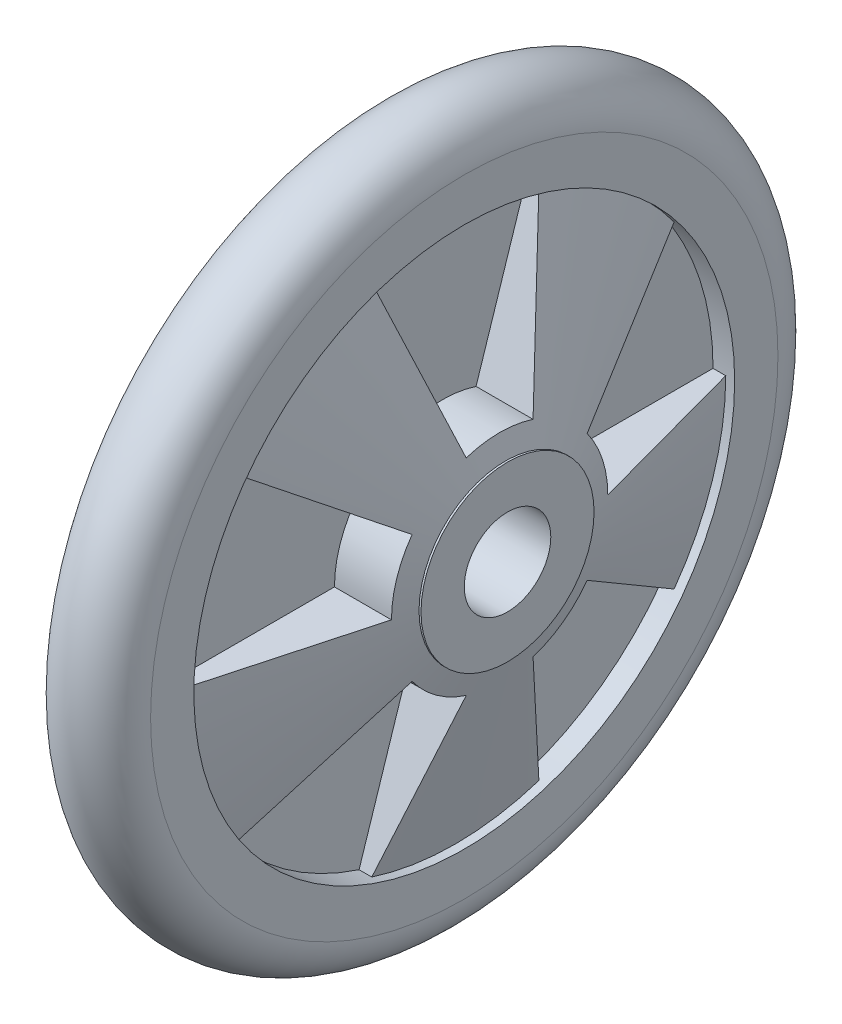
from build123d import *

# Parameters (mm, degrees)
SKETCH4_R            = 72.5
BOSS_EXTRUDE7_DEPTH  = 25
SKETCH13_R           = 72.5
BOSS_EXTRUDE8_DEPTH  = 5
SKETCH14_R           = 20
CUT_EXTRUDE1_DEPTH   = 25
SKETCH15_R           = 20
SKETCH15_R_2         = 10
BOSS_EXTRUDE10_DEPTH = 20


with BuildPart() as part:
    # Sweep1: sweep along a path in Sketch1
    with BuildLine(Plane(origin=(0, 0, 0), x_dir=(0, 0, -1), z_dir=(1, 0, 0))) as sweep1_path:
        CenterArc((0, 0), 72.5, 0, 360)
    # Sketch3 → Sweep1 (sweep)
    with BuildSketch(Plane.XY):
        with BuildLine():
            Line((10, 72.5), (10, 62.5))
            Line((10, 62.5), (-10, 62.5))
            Line((-10, 62.5), (-10, 72.5))
            ThreePointArc((-10, 72.5), (0, 82.5), (10, 72.5))
        make_face()
    sweep(path=sweep1_path.line)



with BuildPart() as body_2:
    # Sketch4 → Boss-Extrude7 (new body, symmetric)
    with BuildSketch(Plane(origin=(0, 0, 0), x_dir=(0, 0, -1), z_dir=(1, 0, 0))):
        Circle(SKETCH4_R)
        with BuildLine():
            Line((25, 0), (62.5, 0))
            ThreePointArc((62.5, 0), (59.441032268, 19.313562148), (50.563562148, 36.736578268))
            Line((50.563562148, 36.736578268), (20.225424859, 14.694631307))
            ThreePointArc((20.225424859, 14.694631307), (23.776412907, 7.725424859), (25, 0))
        make_face(mode=Mode.SUBTRACT)
        with BuildLine():
            Line((7.725424859, 23.776412907), (19.313562148, 59.441032268))
            ThreePointArc((19.313562148, 59.441032268), (0, 62.5), (-19.313562148, 59.441032268))
            Line((-19.313562148, 59.441032268), (-7.725424859, 23.776412907))
            ThreePointArc((-7.725424859, 23.776412907), (0, 25), (7.725424859, 23.776412907))
        make_face(mode=Mode.SUBTRACT)
        with BuildLine():
            Line((7.725424859, -23.776412907), (19.313562148, -59.441032268))
            ThreePointArc((19.313562148, -59.441032268), (36.736578268, -50.563562148), (50.563562148, -36.736578268))
            Line((50.563562148, -36.736578268), (20.225424859, -14.694631307))
            ThreePointArc((20.225424859, -14.694631307), (14.694631307, -20.225424859), (7.725424859, -23.776412907))
        make_face(mode=Mode.SUBTRACT)
        with BuildLine():
            Line((-20.225424859, -14.694631307), (-50.563562148, -36.736578268))
            ThreePointArc((-50.563562148, -36.736578268), (-36.736578268, -50.563562148), (-19.313562148, -59.441032268))
            Line((-19.313562148, -59.441032268), (-7.725424859, -23.776412907))
            ThreePointArc((-7.725424859, -23.776412907), (-14.694631307, -20.225424859), (-20.225424859, -14.694631307))
        make_face(mode=Mode.SUBTRACT)
        with BuildLine():
            Line((-20.225424859, 14.694631307), (-50.563562148, 36.736578268))
            ThreePointArc((-50.563562148, 36.736578268), (-59.441032268, 19.313562148), (-62.5, 0))
            Line((-62.5, 0), (-25, 0))
            ThreePointArc((-25, 0), (-23.776412907, 7.725424859), (-20.225424859, 14.694631307))
        make_face(mode=Mode.SUBTRACT)
    extrude(amount=BOSS_EXTRUDE7_DEPTH, both=True)

    # Sketch12 → Cut-Revolve11 (revolve, cut)
    with BuildSketch(Plane.XY):
        Polygon((-25, 0), (-32.140648249, 0), (-32.140648249, 73.19155482), (-5.016609541, 73.19155482), align=None)
        Polygon((25, 0), (32.140648249, 0), (32.140648249, 73.19155482), (5.016609541, 73.19155482), align=None)
    revolve(axis=Axis((-46.840153715, 0, 0), (1, 0, 0)), mode=Mode.SUBTRACT)


with BuildPart() as part_1:
    add(part.part)

    add(body_2.part)  # Boss-Extrude8 merges body 2
    # Sketch13 → Boss-Extrude8 (add, symmetric)
    with BuildSketch(Plane(origin=(0, 0, 0), x_dir=(0, 0, -1), z_dir=(1, 0, 0))):
        Circle(SKETCH13_R)
    extrude(amount=BOSS_EXTRUDE8_DEPTH, both=True)

    # Sketch14 → Cut-Extrude1 (cut, symmetric)
    with BuildSketch(Plane(origin=(0, 0, 0), x_dir=(0, 0, -1), z_dir=(1, 0, 0))):
        Circle(SKETCH14_R)
    extrude(amount=CUT_EXTRUDE1_DEPTH, both=True, mode=Mode.SUBTRACT)

    # Sketch15 → Boss-Extrude10 (add, symmetric)
    with BuildSketch(Plane(origin=(0, 0, 0), x_dir=(0, 0, -1), z_dir=(1, 0, 0))):
        Circle(SKETCH15_R)
        Circle(SKETCH15_R_2, mode=Mode.SUBTRACT)
    extrude(amount=BOSS_EXTRUDE10_DEPTH, both=True)


solid = part_1.part
